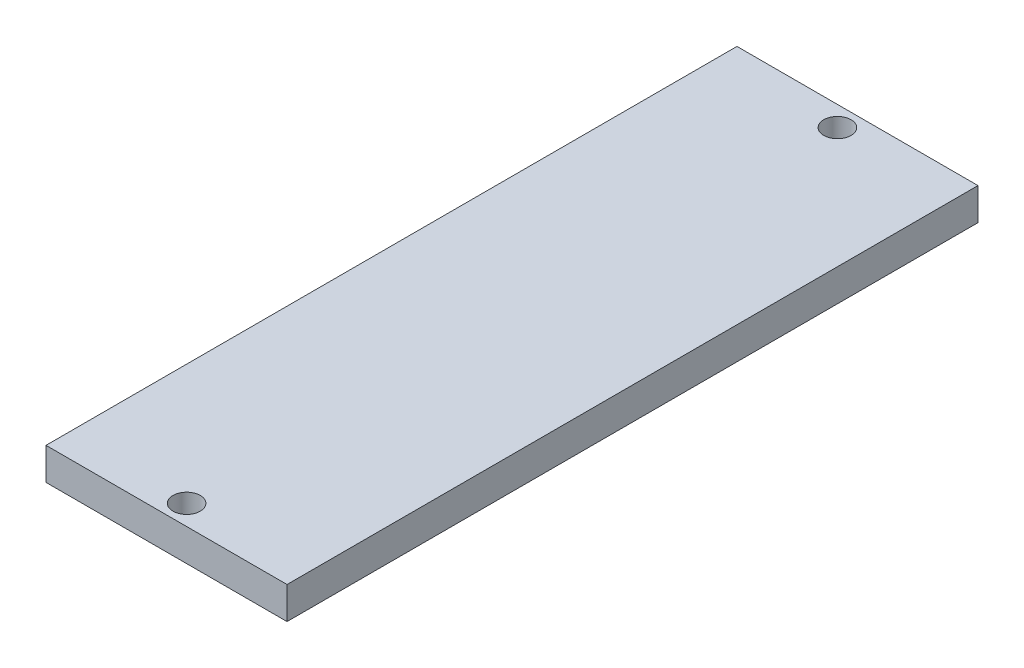
from build123d import *

# Parameters (mm, degrees)
SKETCH_1_W      = 30
SKETCH_1_H      = 86
SKETCH_1_R      = 1.7
EXTRUDE_1_DEPTH = 4


with BuildPart() as part:
    # 草图1 → 凸台-拉伸1 (new body)
    with BuildSketch(Plane(origin=(0, 0, 0), x_dir=(1, 0, 0), z_dir=(0, 1, 0))):
        Rectangle(SKETCH_1_W, SKETCH_1_H)
        with Locations((0, 40.5)):
            Circle(SKETCH_1_R, mode=Mode.SUBTRACT)
        with Locations((0, -40.5)):
            Circle(SKETCH_1_R, mode=Mode.SUBTRACT)
    extrude(amount=EXTRUDE_1_DEPTH)


solid = part.part
